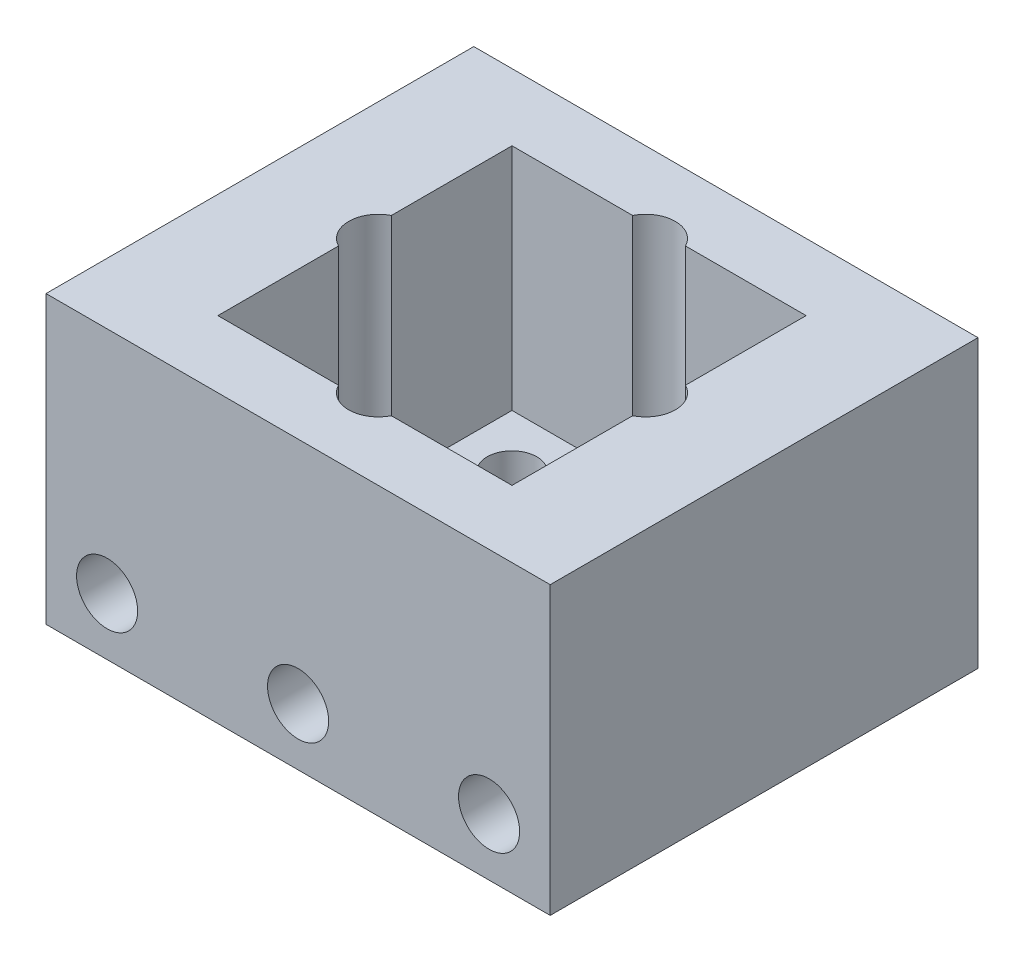
from build123d import *

# Parameters (mm, degrees)
SKETCH_1_W          = 15.4
SKETCH_1_H          = 22.4
EXTRUDE_2_DEPTH     = 3
EXTRUDE_3_DEPTH     = 10
EXTRUDE_3_2_DEPTH   = 10
EXTRUDE_4_DEPTH     = 15
SKETCH_3_R          = 1.6
CUT_EXTRUDE_2_DEPTH = 31.8
SKETCH_9_R          = 1.3
SKETCH_9_R_2        = 3
SKETCH_9_R_3        = 1.55
CUT_EXTRUDE_6_DEPTH = 16
SKETCH_10_R         = 2.9
CUT_EXTRUDE_7_DEPTH = 2


with BuildPart() as part:
    # 草图1 → 凸台-拉伸2 (new body)
    with BuildSketch(Plane(origin=(0, 0, 0), x_dir=(1, 0, 0), z_dir=(0, 1, 0))):
        Rectangle(SKETCH_1_W, SKETCH_1_H)
    extrude(amount=EXTRUDE_2_DEPTH)



with BuildPart() as body_2:
    # 草图1<4> → 凸台-拉伸3 (new body)
    with BuildSketch(Plane(origin=(0, 0, 0), x_dir=(1, 0, 0), z_dir=(0, 1, 0))):
        Polygon((7.7, -11.2), (7.7, -7.7), (0, -7.7), (-4.7, -7.7), (-7.7, -7.7), (-7.7, -11.2), align=None)
    extrude(amount=EXTRUDE_3_DEPTH)


with BuildPart() as body_3:
    # 草图1<4> → Extrude 3 2 (new body)
    with BuildSketch(Plane(origin=(0, 0, 0), x_dir=(1, 0, 0), z_dir=(0, 1, 0))):
        Polygon((-7.7, 7.7), (0, 7.7), (7.7, 7.7), (7.7, 11.2), (-7.7, 11.2), align=None)
    extrude(amount=EXTRUDE_3_2_DEPTH)


with BuildPart() as part_1:
    add(part.part)

    add(body_2.part)  # 凸台-拉伸4 merges body 2

    add(body_3.part)  # 凸台-拉伸4 merges body 3
    # 草图1<5> → 凸台-拉伸4 (add)
    with BuildSketch(Plane(origin=(0, 0, 0), x_dir=(1, 0, 0), z_dir=(0, 1, 0))):
        Polygon((-7.7, 0), (-7.7, 7.7), (-7.7, 11.2), (-13.2, 11.2), (-13.2, -11.2), (-7.7, -11.2), (-7.7, -7.7), align=None)
        Polygon((7.7, 11.2), (7.7, 7.7), (7.7, 0), (7.7, -7.7), (7.7, -11.2), (13.2, -11.2), (13.2, 11.2), align=None)
        Polygon((7.7, -11.2), (7.7, -7.7), (0, -7.7), (-4.7, -7.7), (-7.7, -7.7), (-7.7, -11.2), align=None)
        Polygon((-7.7, 7.7), (0, 7.7), (7.7, 7.7), (7.7, 11.2), (-7.7, 11.2), align=None)
    extrude(amount=EXTRUDE_4_DEPTH)

    # 草图3 → 切除-拉伸2 (cut, through all)
    with BuildSketch(Plane(origin=(0, 0, -19.6), x_dir=(-1, 0, 0), z_dir=(0, 0, -1))):
        with Locations((0, 3)):
            Circle(SKETCH_3_R)
        with Locations((-10, 3)):
            Circle(SKETCH_3_R)
        with Locations((10, 3)):
            Circle(SKETCH_3_R)
    extrude(amount=-CUT_EXTRUDE_2_DEPTH, mode=Mode.SUBTRACT)

    # 草图9 → 切除-拉伸6 (cut, through all)
    with BuildSketch(Plane.XZ):
        with Locations((-4.949747468, -4.949747468)):
            Circle(SKETCH_9_R)
        with Locations((4.949747468, -4.949747468)):
            Circle(SKETCH_9_R)
        with Locations((4.949747468, 4.949747468)):
            Circle(SKETCH_9_R)
        with Locations((-4.949747468, 4.949747468)):
            Circle(SKETCH_9_R)
        Circle(SKETCH_9_R_2)
        with Locations((7, 0)):
            Circle(SKETCH_9_R_3)
        with Locations((0, 7)):
            Circle(SKETCH_9_R_3)
        with Locations((0, -7)):
            Circle(SKETCH_9_R_3)
        with Locations((-7, 0)):
            Circle(SKETCH_9_R_3)
    extrude(amount=-CUT_EXTRUDE_6_DEPTH, mode=Mode.SUBTRACT)

    # 草图10 → 切除-拉伸7 (cut)
    with BuildSketch(Plane(origin=(0, 0, -11.2), x_dir=(-1, 0, 0), z_dir=(0, 0, -1))):
        with Locations((10, 3)):
            Circle(SKETCH_10_R)
        with Locations((0, 3)):
            Circle(SKETCH_10_R)
        with Locations((-10, 3)):
            Circle(SKETCH_10_R)
    extrude(amount=-CUT_EXTRUDE_7_DEPTH, mode=Mode.SUBTRACT)


solid = part_1.part
